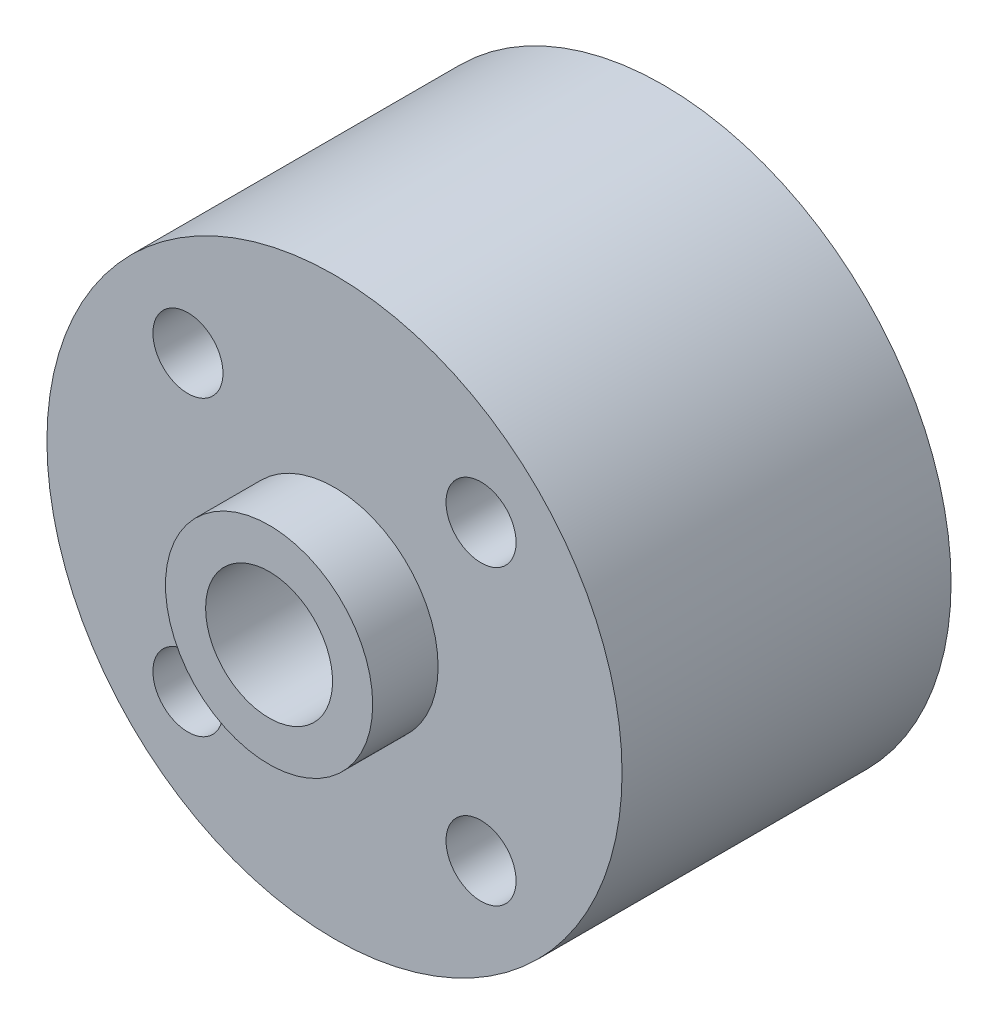
from build123d import *

# Parameters (mm, degrees)
SKETCH1_W                      = 11.1
SKETCH1_H                      = 12.7
SKETCH2_R                      = 4
BOSS_EXTRUDE1_DEPTH            = 2.525
SKETCH3_R                      = 4
BOSS_EXTRUDE2_DEPTH            = 2.525
M2_5_CLEARANCE_HOLE1_D         = 2.705
M2_5_CLEARANCE_HOLE1_DEPTH     = 15.225
F_4_9_4_9_DIAMETER_HOLE1_D     = 4.9
F_4_9_4_9_DIAMETER_HOLE1_DEPTH = 17.75


with BuildPart() as part:
    # Sketch1 → Revolve1 (revolve)
    with BuildSketch(Plane(origin=(0, 0, 0), x_dir=(1, 0, 0), z_dir=(0, 1, 0))):
        with Locations((5.55, 0)):
            Rectangle(SKETCH1_W, SKETCH1_H)
    revolve(axis=Axis((0, 0, -6.35), (0, 0, 1)))

    # Sketch2 → Boss-Extrude1 (add)
    with BuildSketch(Plane(origin=(0, 0, -6.35), x_dir=(-1, 0, 0), z_dir=(0, 0, -1))):
        Circle(SKETCH2_R)
    extrude(amount=BOSS_EXTRUDE1_DEPTH)

    # Sketch3 → Boss-Extrude2 (add)
    with BuildSketch(Plane.XY.offset(6.35)):
        Circle(SKETCH3_R)
    extrude(amount=BOSS_EXTRUDE2_DEPTH)

    # M2.5 Clearance Hole1
    with Locations(Plane.XY.offset(6.35)):
        with Locations((5.656854249, 5.656854249), (-5.656854249, 5.656854249), (-5.656854249, -5.656854249), (5.656854249, -5.656854249)):
            Hole(M2_5_CLEARANCE_HOLE1_D / 2, depth=M2_5_CLEARANCE_HOLE1_DEPTH)

    # Ø4.9 (4.9) Diameter Hole1
    with Locations(Plane(origin=(0, 0, -8.875), x_dir=(-1, 0, 0), z_dir=(0, 0, -1))):
        with Locations((0, 0)):
            Hole(F_4_9_4_9_DIAMETER_HOLE1_D / 2, depth=F_4_9_4_9_DIAMETER_HOLE1_DEPTH)


solid = part.part
